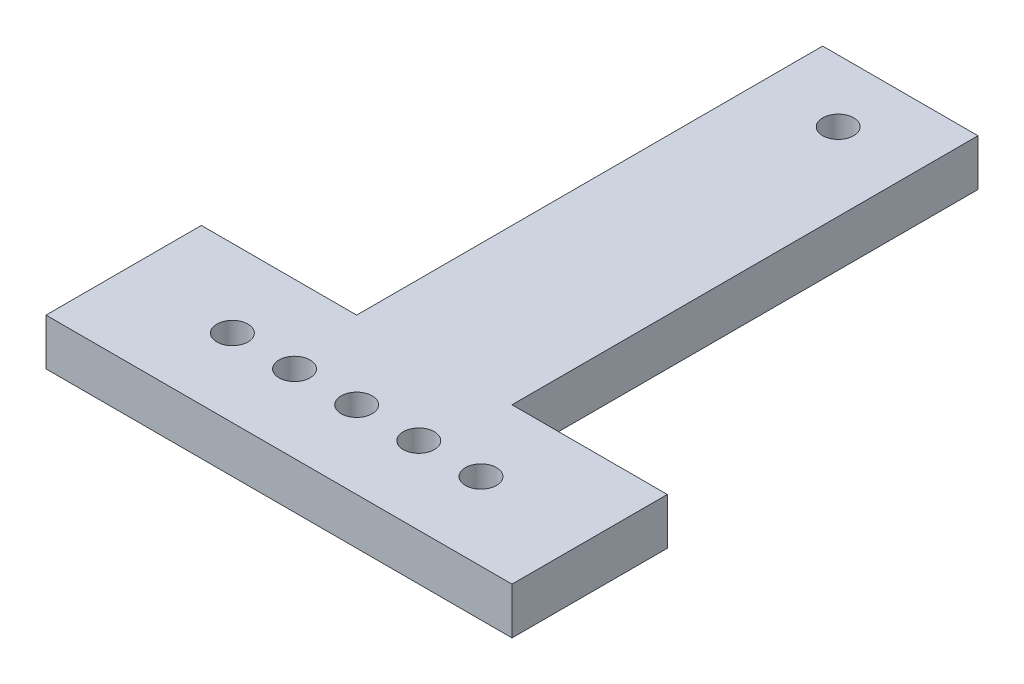
from build123d import *

# Parameters (mm, degrees)
SKETCH1_W           = 50
SKETCH1_H           = 200
BOSS_EXTRUDE1_DEPTH = 15
SKETCH2_R           = 5
CUT_EXTRUDE2_DEPTH  = 16
SKETCH3_W           = 50
SKETCH3_H           = 15
BOSS_EXTRUDE2_DEPTH = 50
SKETCH4_W           = 50
SKETCH4_H           = 15
BOSS_EXTRUDE3_DEPTH = 50
SKETCH5_R           = 5
CUT_EXTRUDE3_DEPTH  = 16


with BuildPart() as part:
    # Sketch1 → Boss-Extrude1 (new body)
    with BuildSketch(Plane(origin=(0, 0, 0), x_dir=(1, 0, 0), z_dir=(0, 1, 0))):
        with Locations((25, 100)):
            Rectangle(SKETCH1_W, SKETCH1_H)
    extrude(amount=BOSS_EXTRUDE1_DEPTH)

    # Sketch2 → Cut-Extrude2 (cut, through all)
    with BuildSketch(Plane(origin=(0, 15, 0), x_dir=(1, 0, 0), z_dir=(0, 1, 0))):
        with Locations((25, 180)):
            Circle(SKETCH2_R)
    extrude(amount=-CUT_EXTRUDE2_DEPTH, mode=Mode.SUBTRACT)

    # Sketch3 → Boss-Extrude2 (add)
    with BuildSketch(Plane(origin=(50, 0, 0), x_dir=(0, 0, -1), z_dir=(1, 0, 0))):
        with Locations((25, 7.5)):
            Rectangle(SKETCH3_W, SKETCH3_H)
    extrude(amount=BOSS_EXTRUDE2_DEPTH)

    # Sketch4 → Boss-Extrude3 (add)
    with BuildSketch(Plane.ZY):
        with Locations((-25, 7.5)):
            Rectangle(SKETCH4_W, SKETCH4_H)
    extrude(amount=BOSS_EXTRUDE3_DEPTH)

    # Sketch5 → Cut-Extrude3 (cut, through all)
    with BuildSketch(Plane(origin=(0, 15, 0), x_dir=(1, 0, 0), z_dir=(0, 1, 0))):
        with Locations((25, 25)):
            Circle(SKETCH5_R)
        with Locations((5, 25)):
            Circle(SKETCH5_R)
        with Locations((-15, 25)):
            Circle(SKETCH5_R)
        with Locations((45, 25)):
            Circle(SKETCH5_R)
        with Locations((65, 25)):
            Circle(SKETCH5_R)
    extrude(amount=-CUT_EXTRUDE3_DEPTH, mode=Mode.SUBTRACT)


solid = part.part
